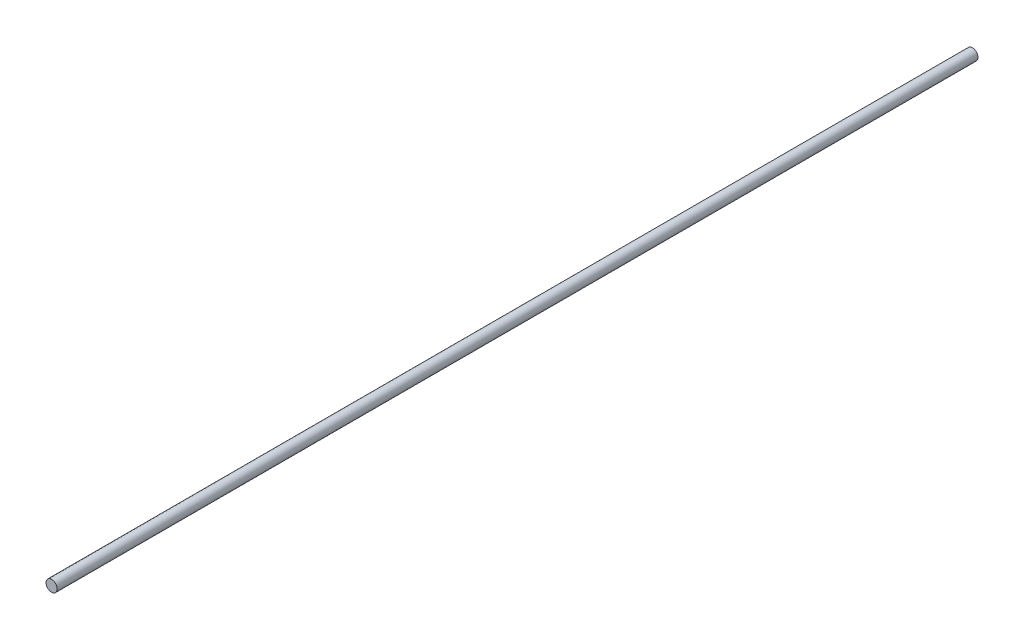
from build123d import *

# Parameters (mm, degrees)
SKETCH1_R           = 2
BOSS_EXTRUDE1_DEPTH = 330


with BuildPart() as part:
    # Sketch1 → Boss-Extrude1 (new body)
    with BuildSketch(Plane.XY):
        Circle(SKETCH1_R)
    extrude(amount=BOSS_EXTRUDE1_DEPTH)


solid = part.part
